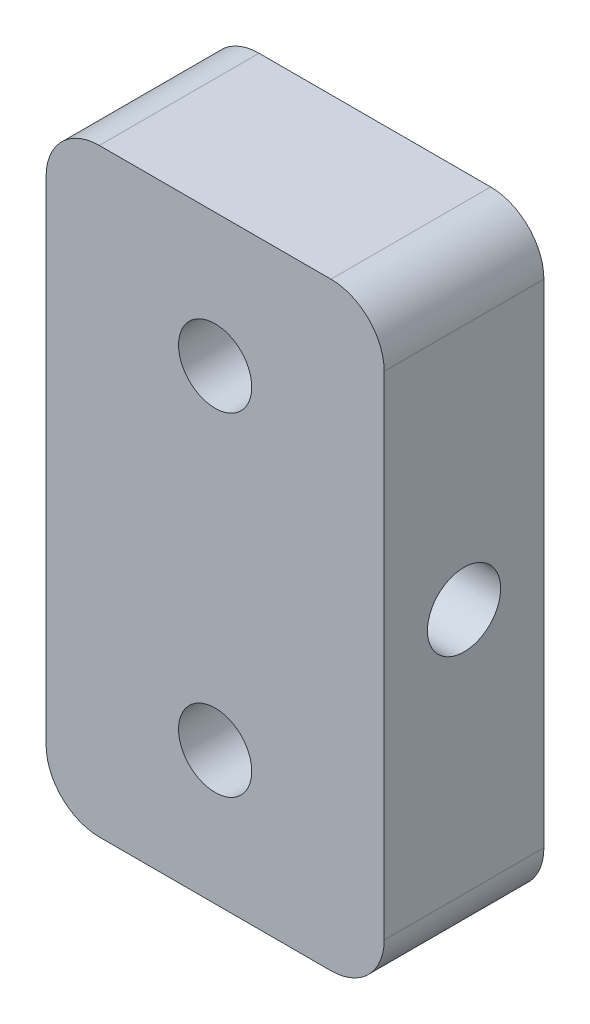
from build123d import *

# Parameters (mm, degrees)
SKETCH1_W            = 25.4
SKETCH1_H            = 45
BOSS_EXTRUDE1_DEPTH  = 6
FILLET1_R            = 4
M5_CLEARANCE_HOLE1_D = 5.5
M5_CLEARANCE_HOLE2_D = 5.5


with BuildPart() as part:
    # Sketch1 → Boss-Extrude1 (new body, symmetric)
    with BuildSketch(Plane.XY):
        Rectangle(SKETCH1_W, SKETCH1_H)
    extrude(amount=BOSS_EXTRUDE1_DEPTH, both=True)

    # Fillet1
    fillet1_edges = [part.edges().sort_by_distance(p)[0] for p in [
        (-12.7, 22.5, 0),
        (12.7, 22.5, 0),
        (12.7, -22.5, 0),
        (-12.7, -22.5, 0),
    ]]
    fillet(fillet1_edges, radius=FILLET1_R)

    # M5 Clearance Hole1 (through all)
    with Locations(Plane.ZY.offset(12.7)):
        with Locations((0, 0)):
            Hole(M5_CLEARANCE_HOLE1_D / 2)

    # M5 Clearance Hole2 (through all)
    with Locations(Plane(origin=(0, 0, -6), x_dir=(-1, 0, 0), z_dir=(0, 0, -1))):
        with Locations((0, 12.5), (0, -12.5)):
            Hole(M5_CLEARANCE_HOLE2_D / 2)


solid = part.part
